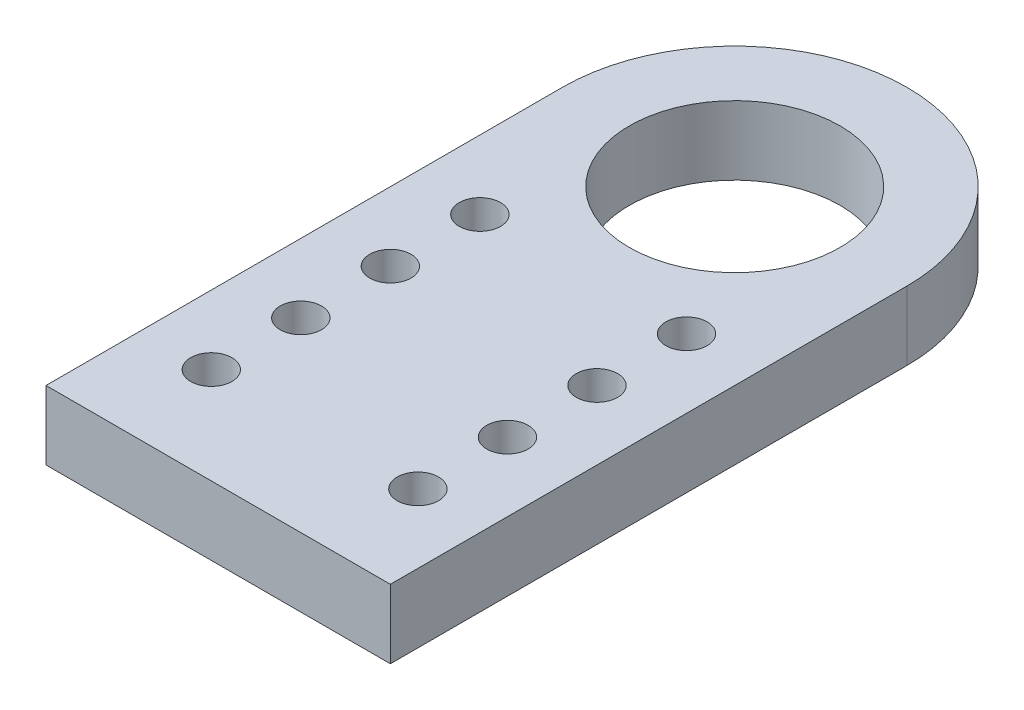
from build123d import *

# Parameters (mm, degrees)
SKETCH_1_R      = 7.65
SKETCH_1_R_2    = 1.5
EXTRUDE_1_DEPTH = 5


with BuildPart() as part:
    # Эскиз1 → Бобышка-Вытянуть1 (new body)
    with BuildSketch(Plane(origin=(0, 0, 0), x_dir=(1, 0, 0), z_dir=(0, 1, 0))):
        with BuildLine():
            Line((-12.5, 15.852233677), (-12.5, -21.647766323))
            Line((-12.5, -21.647766323), (12.5, -21.647766323))
            Line((12.5, -21.647766323), (12.5, 15.852233677))
            ThreePointArc((12.5, 15.852233677), (0, 28.352233677), (-12.5, 15.852233677))
        make_face()
        with Locations((0, 15.852233677)):
            Circle(SKETCH_1_R, mode=Mode.SUBTRACT)
        with Locations((-7.5, -14.647766323)):
            Circle(SKETCH_1_R_2, mode=Mode.SUBTRACT)
        with Locations((7.5, -14.647766323)):
            Circle(SKETCH_1_R_2, mode=Mode.SUBTRACT)
        with Locations((-7.5, -8.147766323)):
            Circle(SKETCH_1_R_2, mode=Mode.SUBTRACT)
        with Locations((7.5, -8.147766323)):
            Circle(SKETCH_1_R_2, mode=Mode.SUBTRACT)
        with Locations((-7.5, -1.647766323)):
            Circle(SKETCH_1_R_2, mode=Mode.SUBTRACT)
        with Locations((7.5, -1.647766323)):
            Circle(SKETCH_1_R_2, mode=Mode.SUBTRACT)
        with Locations((-7.5, 4.852233677)):
            Circle(SKETCH_1_R_2, mode=Mode.SUBTRACT)
        with Locations((7.5, 4.852233677)):
            Circle(SKETCH_1_R_2, mode=Mode.SUBTRACT)
    extrude(amount=EXTRUDE_1_DEPTH)


solid = part.part
